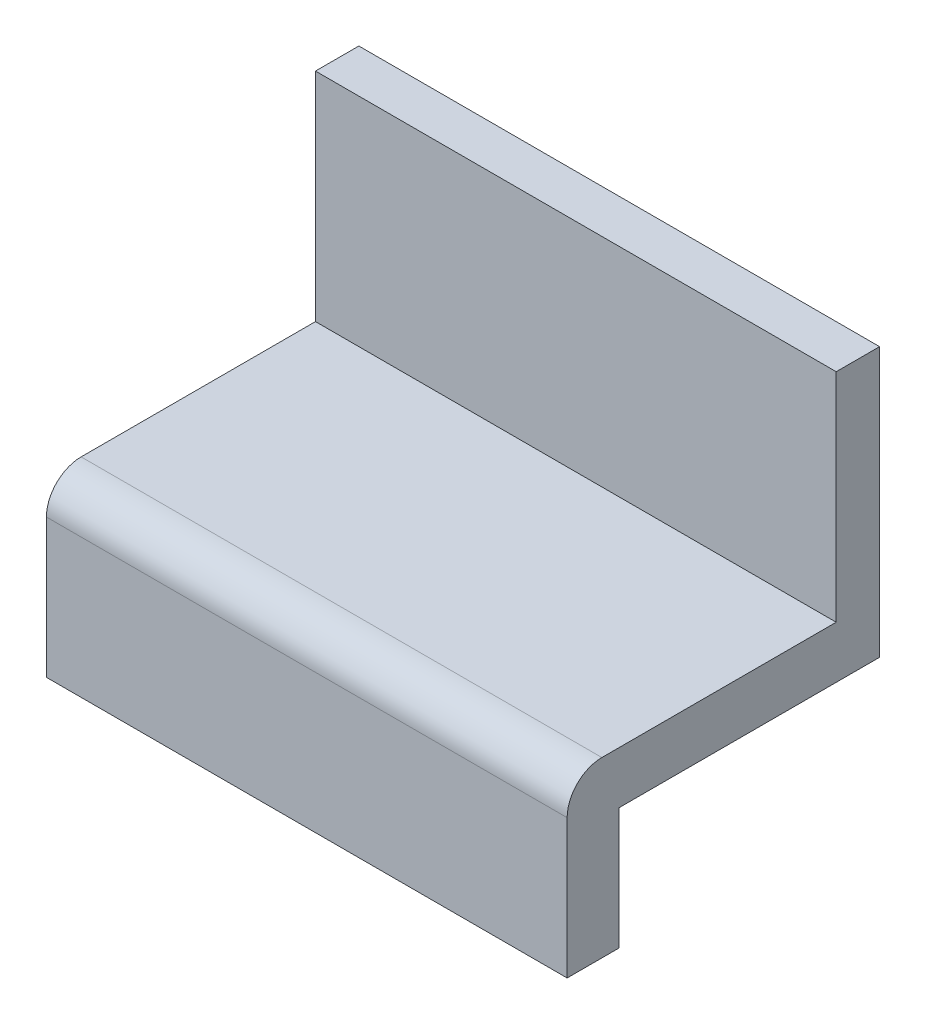
from build123d import *

# Parameters (mm, degrees)
SKETCH_1_W      = 30
SKETCH_1_H      = 18
EXTRUDE_1_DEPTH = 3
SKETCH_2_W      = 30
SKETCH_2_H      = 3
EXTRUDE_2_DEPTH = 7
FILLET_1_R      = 2
SKETCH_5_W      = 30
SKETCH_5_H      = 2.5
EXTRUDE_3_DEPTH = 12.5


with BuildPart() as part:
    # 스케치1 → 보스-돌출1 (new body)
    with BuildSketch(Plane(origin=(0, 0, 0), x_dir=(1, 0, 0), z_dir=(0, 1, 0))):
        Rectangle(SKETCH_1_W, SKETCH_1_H)
    extrude(amount=EXTRUDE_1_DEPTH)

    # 스케치2 → 보스-돌출2 (add)
    with BuildSketch(Plane.XZ):
        with Locations((0, 7.5)):
            Rectangle(SKETCH_2_W, SKETCH_2_H)
    extrude(amount=EXTRUDE_2_DEPTH)

    # 필렛1
    fillet_1_edges = [part.edges().sort_by_distance(p)[0] for p in [
        (0, 3, 9),
    ]]
    fillet(fillet_1_edges, radius=FILLET_1_R)

    # 스케치5 → 보스-돌출3 (add)
    with BuildSketch(Plane(origin=(0, 3, 0), x_dir=(1, 0, 0), z_dir=(0, 1, 0))):
        with Locations((0, 7.75)):
            Rectangle(SKETCH_5_W, SKETCH_5_H)
    extrude(amount=EXTRUDE_3_DEPTH)


solid = part.part
